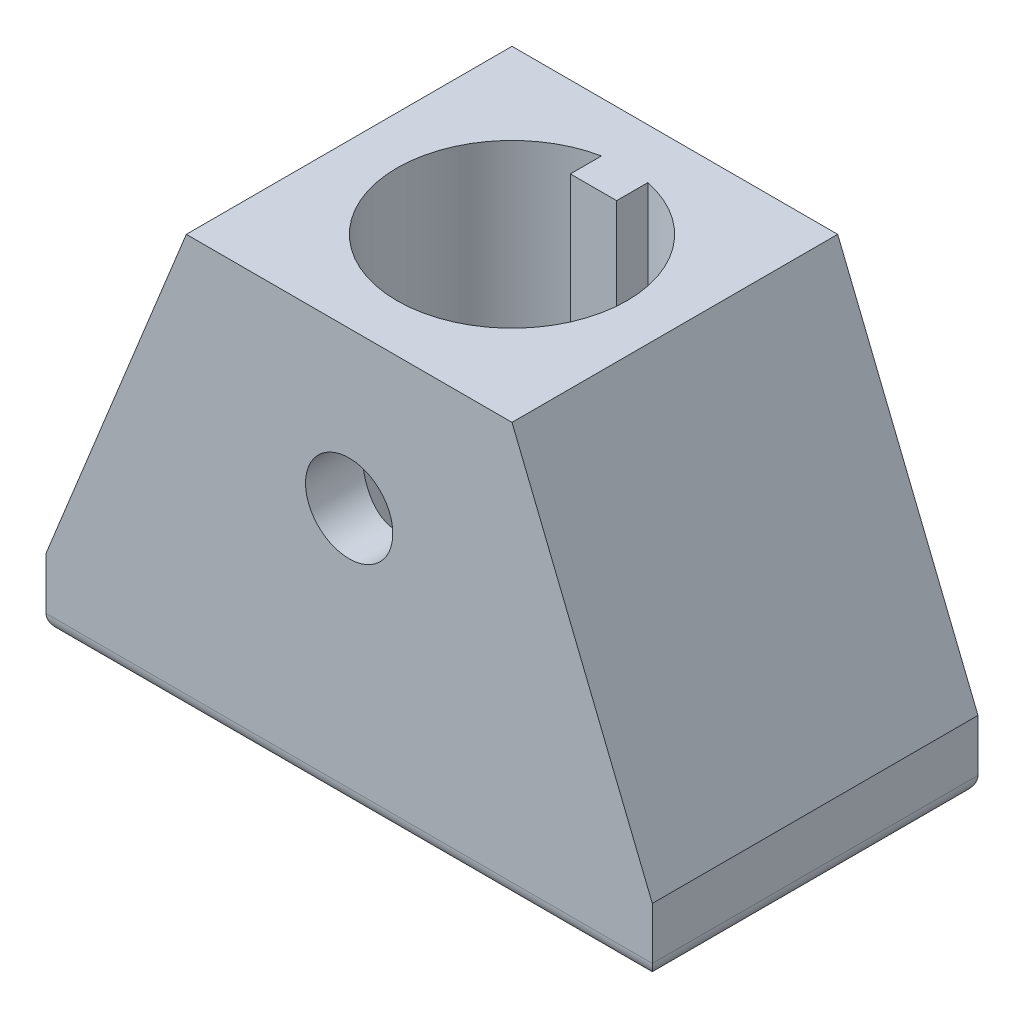
from build123d import *

# Parameters (mm, degrees)
SKETCH1_W           = 18.8
SKETCH1_H           = 18.8
BOSS_EXTRUDE1_DEPTH = 20
SKETCH5_R           = 2.52
CUT_EXTRUDE3_DEPTH  = 15
SKETCH6_W           = 35
SKETCH6_H           = 18.8
BOSS_EXTRUDE2_DEPTH = 4
BOSS_EXTRUDE3_DEPTH = 18.8
FILLET4_R           = 1
CUT_EXTRUDE4_DEPTH  = 4
FILLET5_R           = 0.5


with BuildPart() as part:
    # Sketch1 → Boss-Extrude1 (new body)
    with BuildSketch(Plane(origin=(0, 0, 0), x_dir=(1, 0, 0), z_dir=(0, 1, 0))):
        Rectangle(SKETCH1_W, SKETCH1_H)
        with BuildLine():
            Line((-1.335, 6.504411964), (-1.335, 4.704411964))
            Line((-1.335, 4.704411964), (1.335, 4.704411964))
            Line((1.335, 4.704411964), (1.335, 6.504411964))
            ThreePointArc((1.335, 6.504411964), (0, -6.64), (-1.335, 6.504411964))
        make_face(mode=Mode.SUBTRACT)
    extrude(amount=BOSS_EXTRUDE1_DEPTH)

    # Sketch5 → Cut-Extrude3 (cut)
    with BuildSketch(Plane.XY.offset(-4.704411964)):
        with Locations((-0.000284753, 11.000000005)):
            Circle(SKETCH5_R)
    extrude(amount=CUT_EXTRUDE3_DEPTH, mode=Mode.SUBTRACT)

    # Sketch6 → Boss-Extrude2 (add)
    with BuildSketch(Plane.XZ):
        Rectangle(SKETCH6_W, SKETCH6_H)
    extrude(amount=BOSS_EXTRUDE2_DEPTH)

    # Sketch7 → Boss-Extrude3 (add)
    with BuildSketch(Plane.XY.offset(9.4)):
        Polygon((-9.4, 20), (-9.4, 0), (-17.5, 0), align=None)
        Polygon((9.4, 0), (17.5, 0), (9.4, 20), align=None)
    extrude(amount=-BOSS_EXTRUDE3_DEPTH)

    # Fillet4
    fillet4_edges = [part.edges().sort_by_distance(p)[0] for p in [
        (-17.5, -4, 0),
        (0, -4, -9.4),
        (17.5, -4, 0),
        (0, -4, 9.4),
    ]]
    fillet(fillet4_edges, radius=FILLET4_R)

    # Sketch8 → Cut-Extrude4 (cut)
    with BuildSketch(Plane(origin=(0, 0, 0), x_dir=(1, 0, 0), z_dir=(0, 1, 0))):
        with BuildLine():
            Line((1.335, 4.704411964), (-1.335, 4.704411964))
            Line((-1.335, 4.704411964), (-1.335, 6.504411964))
            ThreePointArc((-1.335, 6.504411964), (0, -6.64), (1.335, 6.504411964))
            Line((1.335, 6.504411964), (1.335, 4.704411964))
        make_face()
    extrude(amount=-CUT_EXTRUDE4_DEPTH, mode=Mode.SUBTRACT)

    # Fillet5
    fillet5_edges = [part.edges().sort_by_distance(p)[0] for p in [
        (0, -4, 6.64),
        (-1.335, -4, -5.604411964),
        (0, -4, -4.704411964),
        (1.335, -4, -5.604411964),
    ]]
    fillet(fillet5_edges, radius=FILLET5_R)


solid = part.part
